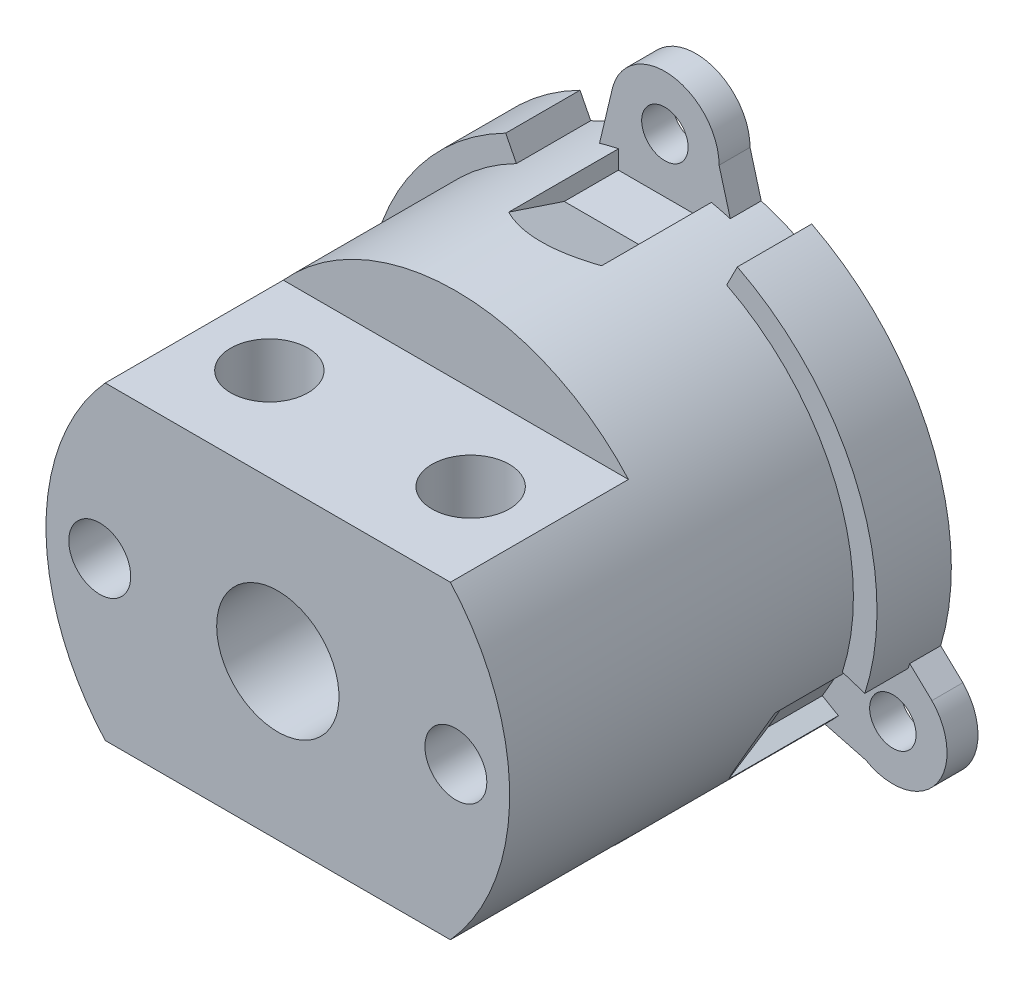
from build123d import *

# Parameters (mm, degrees)
SKETCH1_R                    = 14.975
EXTRUDE1_DEPTH               = 27
EXTRUDE2_DEPTH               = 2
SKETCH3_R                    = 1.5
EXTRUDE3_DEPTH               = 3
EXTRUDE6_DEPTH               = 3
CIRPATTERN1_COUNT            = 3
SKETCH5_W                    = 37.119401026
SKETCH5_H                    = 9.762697639
EXTRUDE7_DEPTH               = 11.5
SKETCH6_R                    = 2.5
EXTRUDE8_DEPTH               = 45.624063274
SKETCH7_R                    = 3.95
EXTRUDE9_DEPTH               = 39.487751598
F_4_0_4_DIAMETER_HOLE1_D     = 4
F_4_0_4_DIAMETER_HOLE1_DEPTH = 15
EXTRUDE10_DEPTH              = 4.8


with BuildPart() as part:
    # Sketch1 → Extrude1 (new body)
    with BuildSketch(Plane.XY):
        Circle(SKETCH1_R)
    extrude(amount=EXTRUDE1_DEPTH)

    # Sketch2 → Extrude2 (add)
    with BuildSketch(Plane.XY):
        with BuildLine():
            Line((-3.363320174, 17.968543962), (-4.221577642, 14.367634016))
            Line((-4.221577642, 14.367634016), (4.221577642, 14.367634016))
            Line((4.221577642, 14.367634016), (3.5, 17))
            ThreePointArc((3.5, 17), (0.489070236, 20.465661597), (-3.363320174, 17.968543962))
        make_face()
    extrude2 = extrude(amount=EXTRUDE2_DEPTH)

    # Sketch3 → Extrude3 (cut)
    with BuildSketch(Plane.XY.offset(2)):
        with Locations((0, 17)):
            Circle(SKETCH3_R)
    extrude3 = extrude(amount=-EXTRUDE3_DEPTH, mode=Mode.SUBTRACT)

    # Sketch4 → Extrude6 (cut, symmetric)
    with BuildSketch(Plane(origin=(0, 0, 0), x_dir=(0, 0, -1), z_dir=(1, 0, 0))):
        Polygon((-2, 14.975), (-2, 13.475), (-5.5, 13.475), (-10, 14.975), align=None)
    extrude6 = extrude(amount=EXTRUDE6_DEPTH, both=True, mode=Mode.SUBTRACT)

    # CirPattern1: Extrude2, Extrude3, Extrude6 ×3 about axis
    cirpattern1_axis = Axis((0, 0, 0), (0, 0, 1))
    add([extrude2.rotate(cirpattern1_axis, i * 360 / CIRPATTERN1_COUNT) for i in range(1, CIRPATTERN1_COUNT)])
    add([extrude3.rotate(cirpattern1_axis, i * 360 / CIRPATTERN1_COUNT) for i in range(1, CIRPATTERN1_COUNT)], mode=Mode.SUBTRACT)
    add([extrude6.rotate(cirpattern1_axis, i * 360 / CIRPATTERN1_COUNT) for i in range(1, CIRPATTERN1_COUNT)], mode=Mode.SUBTRACT)

    # Sketch5 → Extrude7 (cut)
    with BuildSketch(Plane.XY.offset(27)):
        with Locations((1.994416424, 14.88134882)):
            Rectangle(SKETCH5_W, SKETCH5_H)
    extrude7 = extrude(amount=-EXTRUDE7_DEPTH, mode=Mode.SUBTRACT)

    # Mirror2: Extrude7 across plane
    add(extrude7.mirror(Plane.ZX), mode=Mode.SUBTRACT)

    # Sketch6 → Extrude8 (cut, through all)
    with BuildSketch(Plane.XZ.offset(10)):
        with Locations((-6.545813687, 21)):
            Circle(SKETCH6_R)
        with Locations((6.454186313, 21)):
            Circle(SKETCH6_R)
    extrude(amount=-EXTRUDE8_DEPTH, mode=Mode.SUBTRACT)

    # Sketch7 → Extrude9 (cut, through all)
    with BuildSketch(Plane(origin=(0, 0, 0), x_dir=(-1, 0, 0), z_dir=(0, 0, -1))):
        Circle(SKETCH7_R)
    extrude(amount=-EXTRUDE9_DEPTH, mode=Mode.SUBTRACT)

    # Ø4.0 (4) Diameter Hole1
    with Locations(Plane(origin=(-11.5, -0.00158702, 27), x_dir=(1, 0, 0), z_dir=(0, 0, 1))):
        with Locations((0, 0), (23, 0)):
            Hole(F_4_0_4_DIAMETER_HOLE1_D / 2, depth=F_4_0_4_DIAMETER_HOLE1_DEPTH)

    # Sketch9 → Extrude10 (add)
    with BuildSketch(Plane.XY):
        with BuildLine():
            Line((-7.482050917, 14.706084254), (-6.790528029, 13.346885558))
            ThreePointArc((-6.790528029, 13.346885558), (-13.855474408, 5.681237008), (-14.205824206, -4.737634814))
            Line((-14.205824206, -4.737634814), (-15.71367648, -5.032928718))
            ThreePointArc((-15.71367648, -5.032928718), (-15.22884108, 6.350779429), (-7.482050917, 14.706084254))
        make_face()
        with BuildLine():
            Line((7.482050917, 14.706084254), (6.790528029, 13.346885558))
            ThreePointArc((6.790528029, 13.346885558), (13.82132698, 5.763813452), (14.261351836, -4.567764094))
            Line((14.261351836, -4.567764094), (15.71367648, -5.032928718))
            ThreePointArc((15.71367648, -5.032928718), (15.22884108, 6.350779429), (7.482050917, 14.706084254))
        make_face()
    extrude(amount=EXTRUDE10_DEPTH)


solid = part.part
